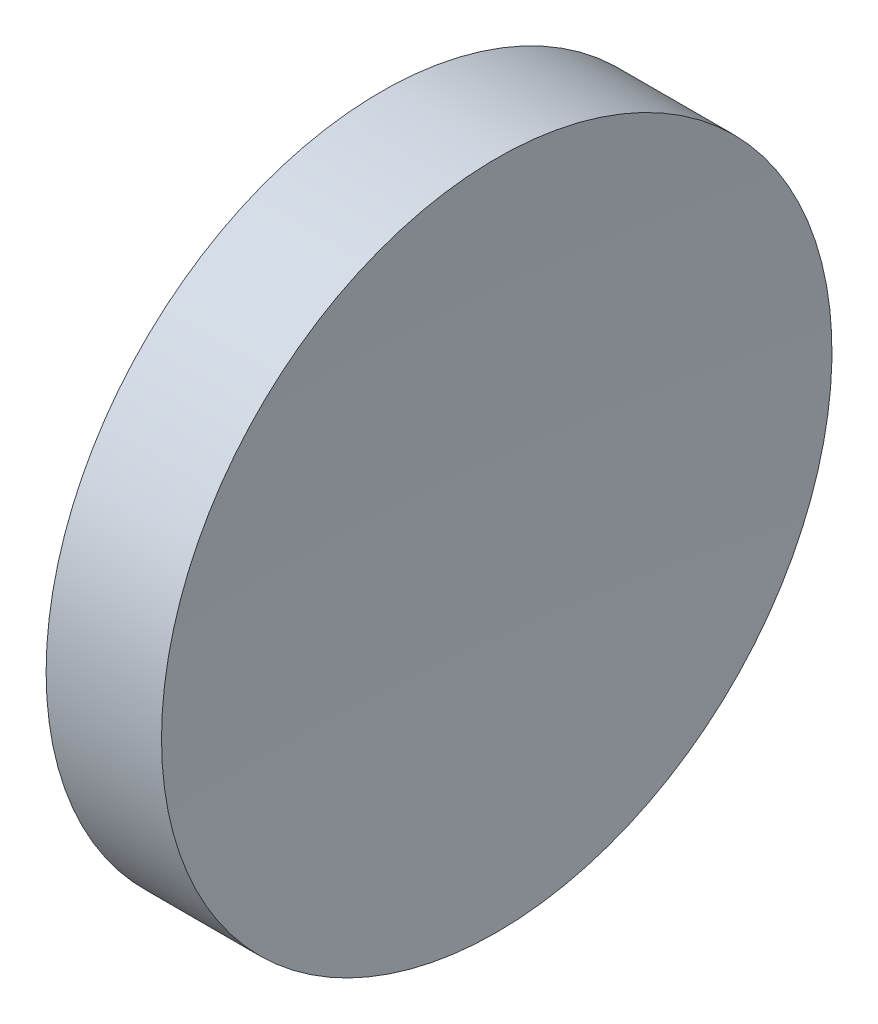
from build123d import *


with BuildPart() as part:
    # 草图1 → 旋转1 (revolve)
    with BuildSketch(Plane.XY, mode=Mode.PRIVATE) as revolve_1_sk:
        with BuildLine():
            Line((119.506834179, 71.193989087), (119.506834179, 83.893989087))
            Line((119.506834179, 83.893989087), (123.878960684, 83.893989087))
            ThreePointArc((123.878960684, 83.893989087), (123.599885765, 77.546714449), (123.506834179, 71.193989087))
            Line((123.506834179, 71.193989087), (119.506834179, 71.193989087))
        make_face()
    revolve(revolve_1_sk.sketch.rotate(Axis((111.955229758, 71.193989087, 0), (1, 0, 0)), 180), axis=Axis((111.955229758, 71.193989087, 0), (1, 0, 0)))  # turned: the seam where the file's is


solid = part.part
